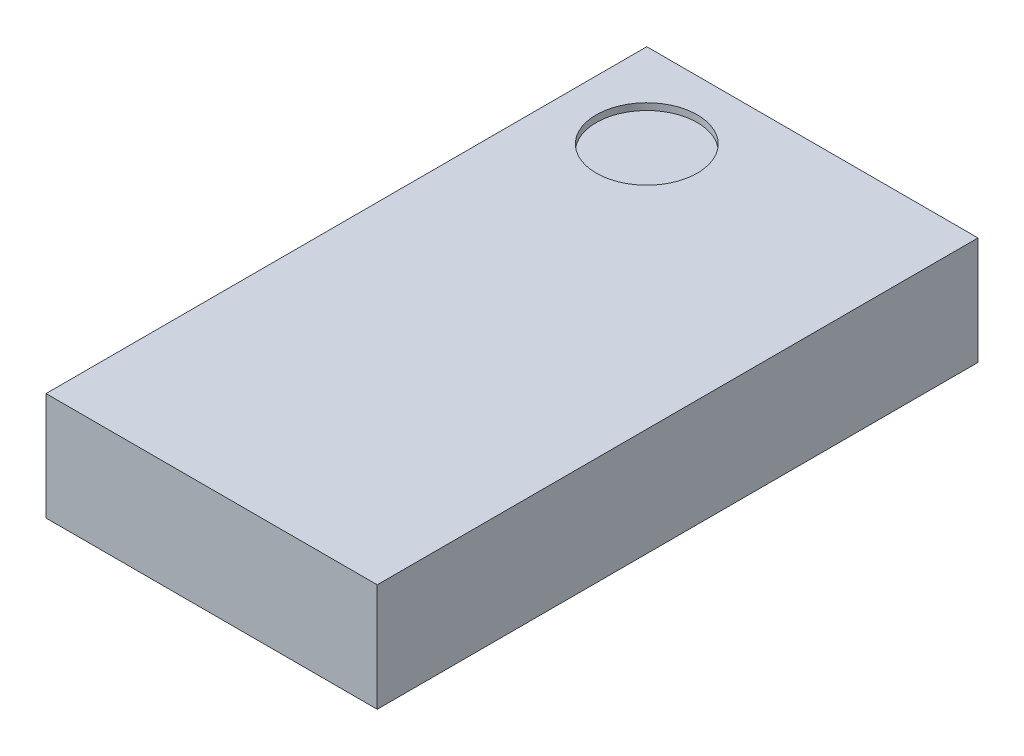
from build123d import *

# Parameters (mm, degrees)
SKETCH1_W            = 0.983
SKETCH1_H            = 1.783
BOSS_EXTRUDE1_DEPTH  = 0.32
LPATTERN1_COUNT      = 4
LPATTERN1_PITCH      = 0.4
LPATTERN1_COUNT_DIR2 = 2
LPATTERN1_PITCH_DIR2 = 0.4
SKETCH3_R            = 0.15
CUT_EXTRUDE1_DEPTH   = 0.02


with BuildPart() as part:
    # Sketch1 → Boss-Extrude1 (new body)
    with BuildSketch(Plane(origin=(0, 0, 0), x_dir=(1, 0, 0), z_dir=(0, 1, 0))):
        Rectangle(SKETCH1_W, SKETCH1_H)
    extrude(amount=BOSS_EXTRUDE1_DEPTH)

    # Sketch2 → Revolve1 (revolve)
    with BuildSketch(Plane.XY.offset(0.6)):
        with BuildLine():
            Line((-0.303923048, 0), (-0.2, 0))
            Line((-0.2, 0), (-0.2, -0.18))
            ThreePointArc((-0.2, -0.18), (-0.303923048, -0.12), (-0.303923048, 0))
        make_face()
    revolve1 = revolve(axis=Axis((-0.2, -0.18, 0.6), (0, 1, 0)))

    # LPattern1: Revolve1 4 × 2
    with Locations(*[(j * LPATTERN1_PITCH_DIR2, 0, -i * LPATTERN1_PITCH) for i in range(LPATTERN1_COUNT) for j in range(LPATTERN1_COUNT_DIR2) if (i, j) != (0, 0)]):
        add(revolve1)

    # Sketch3 → Cut-Extrude1 (cut)
    with BuildSketch(Plane(origin=(0, 0.32, 0), x_dir=(1, 0, 0), z_dir=(0, 1, 0))):
        with Locations((-0.2415, 0.6415)):
            Circle(SKETCH3_R)
    extrude(amount=-CUT_EXTRUDE1_DEPTH, mode=Mode.SUBTRACT)


solid = part.part
